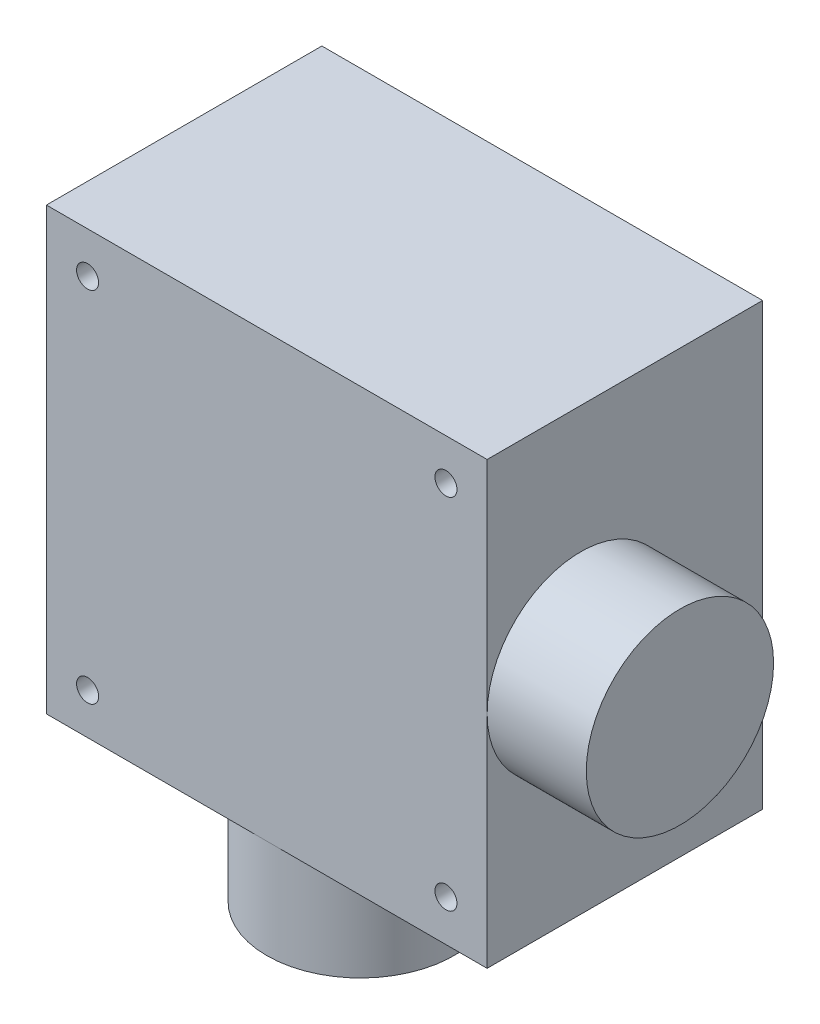
from build123d import *

# Parameters (mm, degrees)
SKETCH1_W           = 40
SKETCH1_H           = 40
BOSS_EXTRUDE1_DEPTH = 25
SKETCH2_R           = 8.5
BOSS_EXTRUDE2_DEPTH = 9
SKETCH3_R           = 1
CUT_EXTRUDE1_DEPTH  = 10


with BuildPart() as part:
    # Sketch1 → Boss-Extrude1 (new body)
    with BuildSketch(Plane.XY):
        Rectangle(SKETCH1_W, SKETCH1_H)
    extrude(amount=BOSS_EXTRUDE1_DEPTH)

    # Sketch2 → Boss-Extrude2 (add)
    with BuildSketch(Plane.XZ.offset(20)):
        with Locations((0, 16.5)):
            Circle(SKETCH2_R)
    boss_extrude2 = extrude(amount=BOSS_EXTRUDE2_DEPTH)

    # Mirror1: Boss-Extrude2 across plane
    add(boss_extrude2.mirror(Plane(origin=(0, 0, 0), x_dir=(0, 0, 1), z_dir=(0.707106781, 0.707106781, 0))))

    # Sketch3 → Cut-Extrude1 (cut)
    with BuildSketch(Plane.XY.offset(25)):
        with Locations((-16.263455967, 16.263455967)):
            Circle(SKETCH3_R)
        with Locations((16.263455967, 16.263455967)):
            Circle(SKETCH3_R)
        with Locations((-16.263455967, -16.263455967)):
            Circle(SKETCH3_R)
        with Locations((16.263455967, -16.263455967)):
            Circle(SKETCH3_R)
    extrude(amount=-CUT_EXTRUDE1_DEPTH, mode=Mode.SUBTRACT)


solid = part.part
